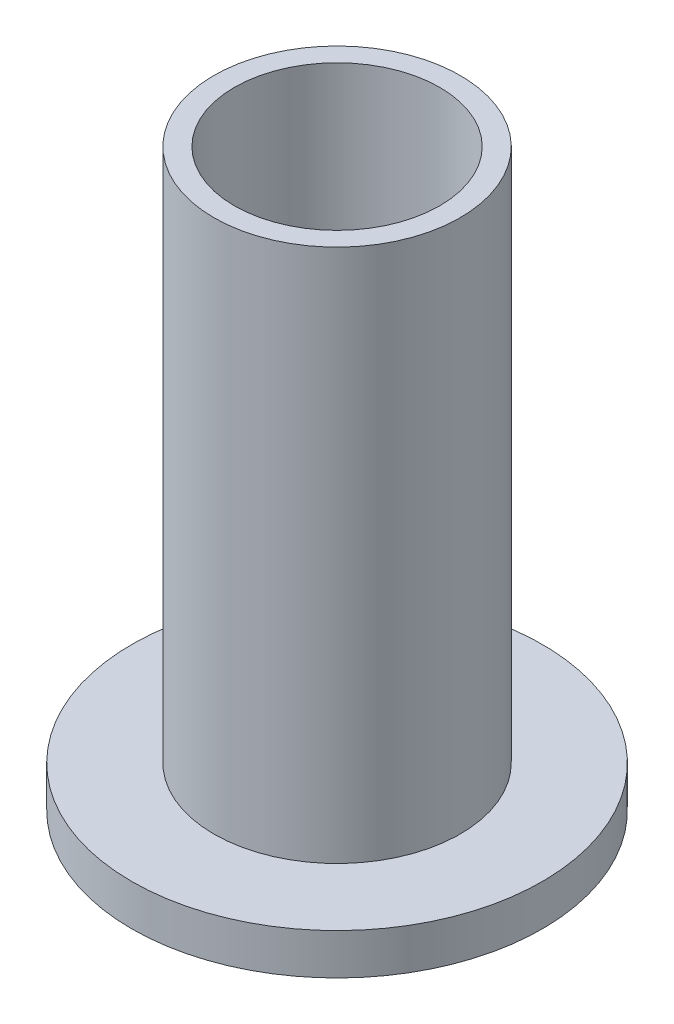
from build123d import *


with BuildPart() as part:
    # Sketch1 → Revolve1 (revolve)
    with BuildSketch(Plane.XY):
        Polygon((-5, 17.14556962), (-5, -10.85443038), (-10, -10.85443038), (-10, -8.85443038), (-6, -8.85443038), (-6, 17.14556962), align=None)
    revolve(axis=Axis((0, 15.284810127, 0), (0, -1, 0)))


solid = part.part
